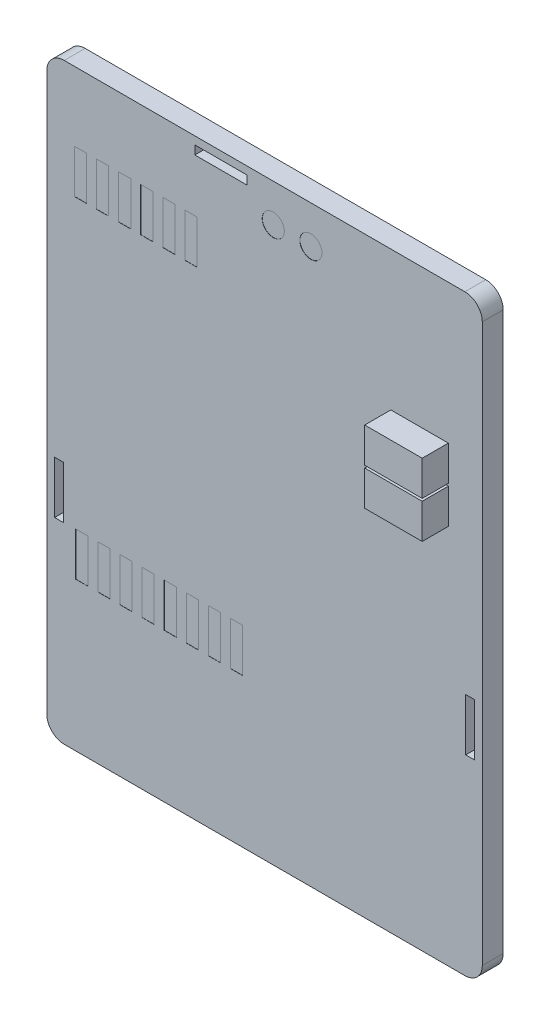
from build123d import *

# Parameters (mm, degrees)
SKETCH_1_W          = 25
SKETCH_1_H          = 34
EXTRUDE_1_DEPTH     = 1.2
SKETCH_1_3_W        = 0.7
SKETCH_1_3_H        = 2.5
SKETCH_1_3_R        = 0.635
CUT_EXTRUDE_1_DEPTH = 0.01
SKETCH_1_4_W        = 3
SKETCH_1_4_H        = 0.5
SKETCH_1_4_W_2      = 0.5
SKETCH_1_4_H_2      = 3
CUT_EXTRUDE_2_DEPTH = 2.2
FILLET_1_R          = 1
SKETCH_1_5_W        = 3.3
SKETCH_1_5_H        = 2
EXTRUDE_2_DEPTH     = 1.5


with BuildPart() as part:
    # Sketch 1 → Extrude 1 (new body)
    with BuildSketch(Plane.XY):
        with Locations((12.5, 17)):
            Rectangle(SKETCH_1_W, SKETCH_1_H)
    extrude(amount=-EXTRUDE_1_DEPTH)

    # Sketch 1_3 → Cut-Extrude 1 (cut)
    with BuildSketch(Plane.XY):
        with Locations((1.93, 28.778)):
            Rectangle(SKETCH_1_3_W, SKETCH_1_3_H)
        with Locations((3.2, 28.778)):
            Rectangle(SKETCH_1_3_W, SKETCH_1_3_H)
        with Locations((5.74, 28.778)):
            Rectangle(SKETCH_1_3_W, SKETCH_1_3_H)
        with Locations((7.01, 28.778)):
            Rectangle(SKETCH_1_3_W, SKETCH_1_3_H)
        with Locations((8.28, 28.778)):
            Rectangle(SKETCH_1_3_W, SKETCH_1_3_H)
        with Locations((13, 31.826)):
            Circle(SKETCH_1_3_R)
        with Locations((15.159, 31.826)):
            Circle(SKETCH_1_3_R)
        with Locations((4.47, 28.778)):
            Rectangle(SKETCH_1_3_W, SKETCH_1_3_H)
        with Locations((2.007, 9.787)):
            Rectangle(SKETCH_1_3_W, SKETCH_1_3_H)
        with Locations((3.277, 9.787)):
            Rectangle(SKETCH_1_3_W, SKETCH_1_3_H)
        with Locations((4.547, 9.787)):
            Rectangle(SKETCH_1_3_W, SKETCH_1_3_H)
        with Locations((5.817, 9.787)):
            Rectangle(SKETCH_1_3_W, SKETCH_1_3_H)
        with Locations((7.087, 9.787)):
            Rectangle(SKETCH_1_3_W, SKETCH_1_3_H)
        with Locations((8.357, 9.787)):
            Rectangle(SKETCH_1_3_W, SKETCH_1_3_H)
        with Locations((9.627, 9.787)):
            Rectangle(SKETCH_1_3_W, SKETCH_1_3_H)
        with Locations((10.897, 9.787)):
            Rectangle(SKETCH_1_3_W, SKETCH_1_3_H)
    extrude(amount=-CUT_EXTRUDE_1_DEPTH, mode=Mode.SUBTRACT)

    # Sketch 1_4 → Cut-Extrude 2 (cut, through all)
    with BuildSketch(Plane.XY):
        with Locations((10, 33.3)):
            Rectangle(SKETCH_1_4_W, SKETCH_1_4_H)
        with Locations((0.7, 12.5)):
            Rectangle(SKETCH_1_4_W_2, SKETCH_1_4_H_2)
        with Locations((24.3, 12.5)):
            Rectangle(SKETCH_1_4_W_2, SKETCH_1_4_H_2)
    extrude(amount=-CUT_EXTRUDE_2_DEPTH, mode=Mode.SUBTRACT)

    # Fillet 1
    fillet_1_edges = [part.edges().sort_by_distance(p)[0] for p in [
        (0, 0, -0.6),
        (0, 34, -0.6),
        (25, 34, -0.6),
        (25, 0, -0.6),
    ]]
    fillet(fillet_1_edges, radius=FILLET_1_R)

    # Sketch 1_5 → Extrude 2 (add)
    with BuildSketch(Plane.XY):
        with Locations((21.4, 25)):
            Rectangle(SKETCH_1_5_W, SKETCH_1_5_H)
        with Locations((21.4, 22.86)):
            Rectangle(SKETCH_1_5_W, SKETCH_1_5_H)
    extrude(amount=EXTRUDE_2_DEPTH)


solid = part.part
